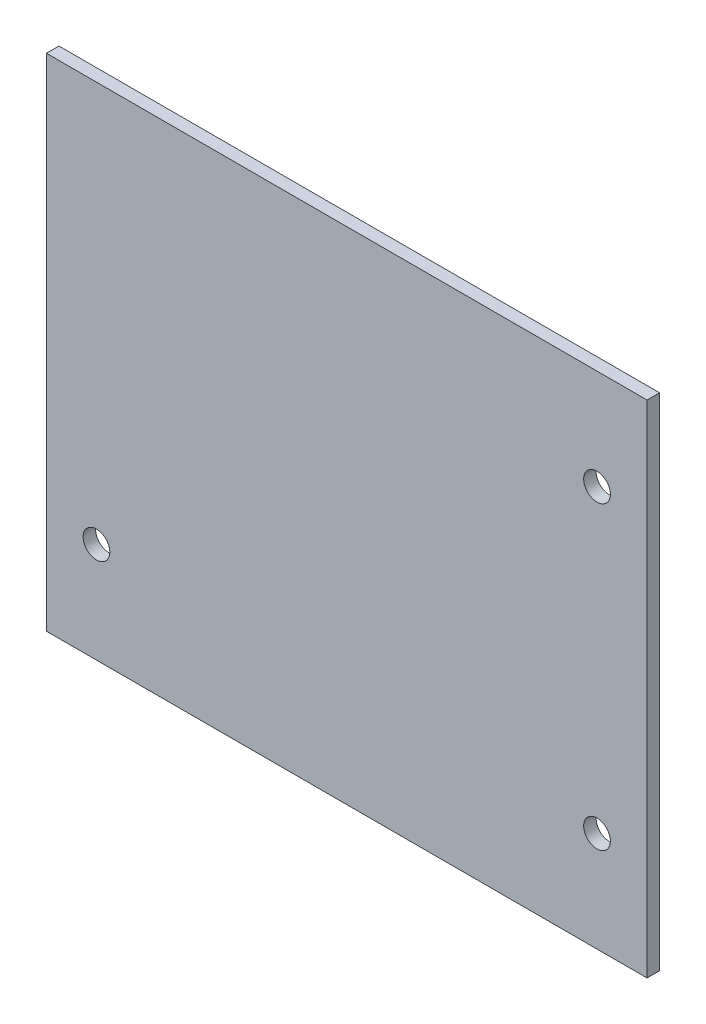
from build123d import *

# Parameters (mm, degrees)
SKETCH1_W           = 152.4
SKETCH1_H           = 127
SKETCH1_R           = 3.3909
BOSS_EXTRUDE1_DEPTH = 3.175


with BuildPart() as part:
    # Sketch1 → Boss-Extrude1 (new body)
    with BuildSketch(Plane.XY):
        Rectangle(SKETCH1_W, SKETCH1_H)
        with Locations((63.5, 38.1)):
            Circle(SKETCH1_R, mode=Mode.SUBTRACT)
        with Locations((63.5, -38.1)):
            Circle(SKETCH1_R, mode=Mode.SUBTRACT)
        with Locations((-63.5, -38.1)):
            Circle(SKETCH1_R, mode=Mode.SUBTRACT)
    extrude(amount=BOSS_EXTRUDE1_DEPTH)


solid = part.part
